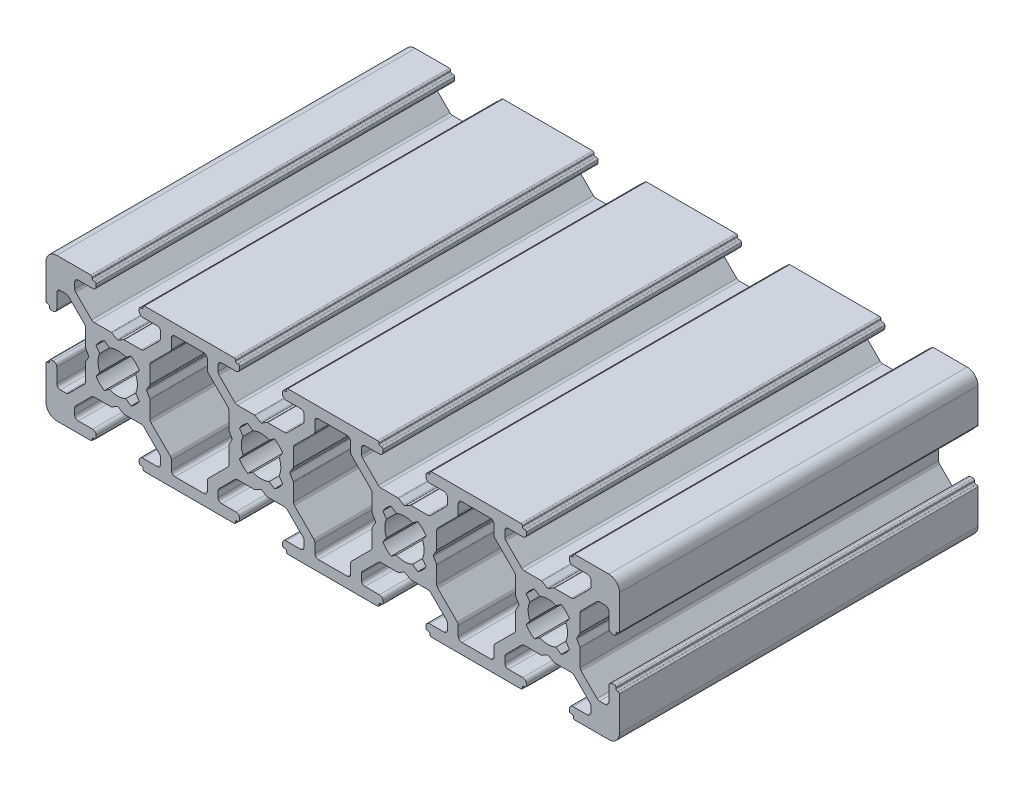
from build123d import *

# Parameters (mm, degrees)
EXTRUDE_1_DEPTH = 50


with BuildPart() as part:
    # Эскиз1 → Бобышка-Вытянуть1 (new body)
    with BuildSketch(Plane.XY):
        with BuildLine():
            Line((-13.645430713, 4.646446609), (-15.853553391, 6.854569287))
            ThreePointArc((-15.853553391, 6.854569287), (-15.961939766, 7.016780961), (-16, 7.208122677))
            Line((-16, 7.208122677), (-16, 8))
            ThreePointArc((-16, 8), (-15.853553391, 8.353553391), (-15.5, 8.5))
            Line((-15.5, 8.5), (-13.5, 8.5))
            ThreePointArc((-13.5, 8.5), (-13.146446609, 8.646446609), (-13, 9))
            Line((-13, 9), (-13, 9.3))
            ThreePointArc((-13, 9.3), (-13.058578644, 9.441421356), (-13.2, 9.5))
            Line((-13.2, 9.5), (-13.35, 9.5))
            ThreePointArc((-13.35, 9.5), (-13.491421356, 9.558578644), (-13.55, 9.7))
            Line((-13.55, 9.7), (-13.55, 9.8))
            ThreePointArc((-13.55, 9.8), (-13.608578644, 9.941421356), (-13.75, 10))
            Line((-13.75, 10), (-18.5, 10))
            ThreePointArc((-18.5, 10), (-19.560660172, 9.560660172), (-20, 8.5))
            Line((-20, 8.5), (-20, 3.75))
            ThreePointArc((-20, 3.75), (-19.941421356, 3.608578644), (-19.8, 3.55))
            Line((-19.8, 3.55), (-19.7, 3.55))
            ThreePointArc((-19.7, 3.55), (-19.558578644, 3.491421356), (-19.5, 3.35))
            Line((-19.5, 3.35), (-19.5, 3.2))
            ThreePointArc((-19.5, 3.2), (-19.441421356, 3.058578644), (-19.3, 3))
            Line((-19.3, 3), (-19, 3))
            ThreePointArc((-19, 3), (-18.646446609, 3.146446609), (-18.5, 3.5))
            Line((-18.5, 3.5), (-18.5, 5.5))
            ThreePointArc((-18.5, 5.5), (-18.353553391, 5.853553391), (-18, 6))
            Line((-18, 6), (-17.208122677, 6))
            ThreePointArc((-17.208122677, 6), (-17.016780961, 5.961939766), (-16.854569287, 5.853553391))
            Line((-16.854569287, 5.853553391), (-14.646446609, 3.645430713))
            ThreePointArc((-14.646446609, 3.645430713), (-14.538060234, 3.483219039), (-14.5, 3.291877323))
            Line((-14.5, 3.291877323), (-14.5, 0.919615242))
            ThreePointArc((-14.5, 0.919615242), (-14.493185165, 0.867851433), (-14.473205081, 0.819615242))
            Line((-14.473205081, 0.819615242), (-14.057735027, 0.1))
            ThreePointArc((-14.057735027, 0.1), (-14.030940108, 0), (-14.057735027, -0.1))
            Line((-14.057735027, -0.1), (-14.473205081, -0.819615242))
            ThreePointArc((-14.473205081, -0.819615242), (-14.493185165, -0.867851433), (-14.5, -0.919615242))
            Line((-14.5, -0.919615242), (-14.5, -3.291877323))
            ThreePointArc((-14.5, -3.291877323), (-14.538060234, -3.483219039), (-14.646446609, -3.645430713))
            Line((-14.646446609, -3.645430713), (-16.854569287, -5.853553391))
            ThreePointArc((-16.854569287, -5.853553391), (-17.016780961, -5.961939766), (-17.208122677, -6))
            Line((-17.208122677, -6), (-18, -6))
            ThreePointArc((-18, -6), (-18.353553391, -5.853553391), (-18.5, -5.5))
            Line((-18.5, -5.5), (-18.5, -3.5))
            ThreePointArc((-18.5, -3.5), (-18.646446609, -3.146446609), (-19, -3))
            Line((-19, -3), (-19.3, -3))
            ThreePointArc((-19.3, -3), (-19.441421356, -3.058578644), (-19.5, -3.2))
            Line((-19.5, -3.2), (-19.5, -3.35))
            ThreePointArc((-19.5, -3.35), (-19.558578644, -3.491421356), (-19.7, -3.55))
            Line((-19.7, -3.55), (-19.8, -3.55))
            ThreePointArc((-19.8, -3.55), (-19.941421356, -3.608578644), (-20, -3.75))
            Line((-20, -3.75), (-20, -8.5))
            ThreePointArc((-20, -8.5), (-19.560660172, -9.560660172), (-18.5, -10))
            Line((-18.5, -10), (-13.75, -10))
            ThreePointArc((-13.75, -10), (-13.608578644, -9.941421356), (-13.55, -9.8))
            Line((-13.55, -9.8), (-13.55, -9.7))
            ThreePointArc((-13.55, -9.7), (-13.491421356, -9.558578644), (-13.35, -9.5))
            Line((-13.35, -9.5), (-13.2, -9.5))
            ThreePointArc((-13.2, -9.5), (-13.058578644, -9.441421356), (-13, -9.3))
            Line((-13, -9.3), (-13, -9))
            ThreePointArc((-13, -9), (-13.146446609, -8.646446609), (-13.5, -8.5))
            Line((-13.5, -8.5), (-15.5, -8.5))
            ThreePointArc((-15.5, -8.5), (-15.853553391, -8.353553391), (-16, -8))
            Line((-16, -8), (-16, -7.208122677))
            ThreePointArc((-16, -7.208122677), (-15.961939766, -7.016780961), (-15.853553391, -6.854569287))
            Line((-15.853553391, -6.854569287), (-13.645430713, -4.646446609))
            ThreePointArc((-13.645430713, -4.646446609), (-13.483219039, -4.538060234), (-13.291877323, -4.5))
            Line((-13.291877323, -4.5), (-10.919615242, -4.5))
            ThreePointArc((-10.919615242, -4.5), (-10.867851433, -4.493185165), (-10.819615242, -4.473205081))
            Line((-10.819615242, -4.473205081), (-10.1, -4.057735027))
            ThreePointArc((-10.1, -4.057735027), (-10, -4.030940108), (-9.9, -4.057735027))
            Line((-9.9, -4.057735027), (-9.180384758, -4.473205081))
            ThreePointArc((-9.180384758, -4.473205081), (-9.132148567, -4.493185165), (-9.080384758, -4.5))
            Line((-9.080384758, -4.5), (-6.708122677, -4.5))
            ThreePointArc((-6.708122677, -4.5), (-6.516780961, -4.538060234), (-6.354569287, -4.646446609))
            Line((-6.354569287, -4.646446609), (-4.146446609, -6.854569287))
            ThreePointArc((-4.146446609, -6.854569287), (-4.038060234, -7.016780961), (-4, -7.208122677))
            Line((-4, -7.208122677), (-4, -8))
            ThreePointArc((-4, -8), (-4.146446609, -8.353553391), (-4.5, -8.5))
            Line((-4.5, -8.5), (-6.5, -8.5))
            ThreePointArc((-6.5, -8.5), (-6.853553391, -8.646446609), (-7, -9))
            Line((-7, -9), (-7, -9.3))
            ThreePointArc((-7, -9.3), (-6.941421356, -9.441421356), (-6.8, -9.5))
            Line((-6.8, -9.5), (-6.65, -9.5))
            ThreePointArc((-6.65, -9.5), (-6.508578644, -9.558578644), (-6.45, -9.7))
            Line((-6.45, -9.7), (-6.45, -9.8))
            ThreePointArc((-6.45, -9.8), (-6.391421356, -9.941421356), (-6.25, -10))
            Line((-6.25, -10), (6.25, -10))
            ThreePointArc((6.25, -10), (6.391421356, -9.941421356), (6.45, -9.8))
            Line((6.45, -9.8), (6.45, -9.7))
            ThreePointArc((6.45, -9.7), (6.508578644, -9.558578644), (6.65, -9.5))
            Line((6.65, -9.5), (6.8, -9.5))
            ThreePointArc((6.8, -9.5), (6.941421356, -9.441421356), (7, -9.3))
            Line((7, -9.3), (7, -9))
            ThreePointArc((7, -9), (6.853553391, -8.646446609), (6.5, -8.5))
            Line((6.5, -8.5), (4.5, -8.5))
            ThreePointArc((4.5, -8.5), (4.146446609, -8.353553391), (4, -8))
            Line((4, -8), (4, -7.208122677))
            ThreePointArc((4, -7.208122677), (4.038060234, -7.016780961), (4.146446609, -6.854569287))
            Line((4.146446609, -6.854569287), (6.354569287, -4.646446609))
            ThreePointArc((6.354569287, -4.646446609), (6.516780961, -4.538060234), (6.708122677, -4.5))
            Line((6.708122677, -4.5), (9.080384758, -4.5))
            ThreePointArc((9.080384758, -4.5), (9.132148567, -4.493185165), (9.180384758, -4.473205081))
            Line((9.180384758, -4.473205081), (9.9, -4.057735027))
            ThreePointArc((9.9, -4.057735027), (10, -4.030940108), (10.1, -4.057735027))
            Line((10.1, -4.057735027), (10.819615242, -4.473205081))
            ThreePointArc((10.819615242, -4.473205081), (10.867851433, -4.493185165), (10.919615242, -4.5))
            Line((10.919615242, -4.5), (13.291877323, -4.5))
            ThreePointArc((13.291877323, -4.5), (13.483219039, -4.538060234), (13.645430713, -4.646446609))
            Line((13.645430713, -4.646446609), (15.853553391, -6.854569287))
            ThreePointArc((15.853553391, -6.854569287), (15.961939766, -7.016780961), (16, -7.208122677))
            Line((16, -7.208122677), (16, -8))
            ThreePointArc((16, -8), (15.853553391, -8.353553391), (15.5, -8.5))
            Line((15.5, -8.5), (13.5, -8.5))
            ThreePointArc((13.5, -8.5), (13.146446609, -8.646446609), (13, -9))
            Line((13, -9), (13, -9.3))
            ThreePointArc((13, -9.3), (13.058578644, -9.441421356), (13.2, -9.5))
            Line((13.2, -9.5), (13.35, -9.5))
            ThreePointArc((13.35, -9.5), (13.491421356, -9.558578644), (13.55, -9.7))
            Line((13.55, -9.7), (13.55, -9.8))
            ThreePointArc((13.55, -9.8), (13.608578644, -9.941421356), (13.75, -10))
            Line((13.75, -10), (26.25, -10))
            ThreePointArc((26.25, -10), (26.391421356, -9.941421356), (26.45, -9.8))
            Line((26.45, -9.8), (26.45, -9.7))
            ThreePointArc((26.45, -9.7), (26.508578644, -9.558578644), (26.65, -9.5))
            Line((26.65, -9.5), (26.8, -9.5))
            ThreePointArc((26.8, -9.5), (26.941421356, -9.441421356), (27, -9.3))
            Line((27, -9.3), (27, -9))
            ThreePointArc((27, -9), (26.853553391, -8.646446609), (26.5, -8.5))
            Line((26.5, -8.5), (24.5, -8.5))
            ThreePointArc((24.5, -8.5), (24.146446609, -8.353553391), (24, -8))
            Line((24, -8), (24, -7.208122677))
            ThreePointArc((24, -7.208122677), (24.038060234, -7.016780961), (24.146446609, -6.854569287))
            Line((24.146446609, -6.854569287), (26.354569287, -4.646446609))
            ThreePointArc((26.354569287, -4.646446609), (26.516780961, -4.538060234), (26.708122677, -4.5))
            Line((26.708122677, -4.5), (29.080384758, -4.5))
            ThreePointArc((29.080384758, -4.5), (29.132148567, -4.493185165), (29.180384758, -4.473205081))
            Line((29.180384758, -4.473205081), (29.9, -4.057735027))
            ThreePointArc((29.9, -4.057735027), (30, -4.030940108), (30.1, -4.057735027))
            Line((30.1, -4.057735027), (30.819615242, -4.473205081))
            ThreePointArc((30.819615242, -4.473205081), (30.867851433, -4.493185165), (30.919615242, -4.5))
            Line((30.919615242, -4.5), (33.291877323, -4.5))
            ThreePointArc((33.291877323, -4.5), (33.483219039, -4.538060234), (33.645430713, -4.646446609))
            Line((33.645430713, -4.646446609), (35.853553391, -6.854569287))
            ThreePointArc((35.853553391, -6.854569287), (35.961939766, -7.016780961), (36, -7.208122677))
            Line((36, -7.208122677), (36, -8))
            ThreePointArc((36, -8), (35.853553391, -8.353553391), (35.5, -8.5))
            Line((35.5, -8.5), (33.5, -8.5))
            ThreePointArc((33.5, -8.5), (33.146446609, -8.646446609), (33, -9))
            Line((33, -9), (33, -9.3))
            ThreePointArc((33, -9.3), (33.058578644, -9.441421356), (33.2, -9.5))
            Line((33.2, -9.5), (33.35, -9.5))
            ThreePointArc((33.35, -9.5), (33.491421356, -9.558578644), (33.55, -9.7))
            Line((33.55, -9.7), (33.55, -9.8))
            ThreePointArc((33.55, -9.8), (33.608578644, -9.941421356), (33.75, -10))
            Line((33.75, -10), (46.25, -10))
            ThreePointArc((46.25, -10), (46.391421356, -9.941421356), (46.45, -9.8))
            Line((46.45, -9.8), (46.45, -9.7))
            ThreePointArc((46.45, -9.7), (46.508578644, -9.558578644), (46.65, -9.5))
            Line((46.65, -9.5), (46.8, -9.5))
            ThreePointArc((46.8, -9.5), (46.941421356, -9.441421356), (47, -9.3))
            Line((47, -9.3), (47, -9))
            ThreePointArc((47, -9), (46.853553391, -8.646446609), (46.5, -8.5))
            Line((46.5, -8.5), (44.5, -8.5))
            ThreePointArc((44.5, -8.5), (44.146446609, -8.353553391), (44, -8))
            Line((44, -8), (44, -7.208122677))
            ThreePointArc((44, -7.208122677), (44.038060234, -7.016780961), (44.146446609, -6.854569287))
            Line((44.146446609, -6.854569287), (46.354569287, -4.646446609))
            ThreePointArc((46.354569287, -4.646446609), (46.516780961, -4.538060234), (46.708122677, -4.5))
            Line((46.708122677, -4.5), (49.080384758, -4.5))
            ThreePointArc((49.080384758, -4.5), (49.132148567, -4.493185165), (49.180384758, -4.473205081))
            Line((49.180384758, -4.473205081), (49.9, -4.057735027))
            ThreePointArc((49.9, -4.057735027), (50, -4.030940108), (50.1, -4.057735027))
            Line((50.1, -4.057735027), (50.819615242, -4.473205081))
            ThreePointArc((50.819615242, -4.473205081), (50.867851433, -4.493185165), (50.919615242, -4.5))
            Line((50.919615242, -4.5), (53.291877323, -4.5))
            ThreePointArc((53.291877323, -4.5), (53.483219039, -4.538060234), (53.645430713, -4.646446609))
            Line((53.645430713, -4.646446609), (55.853553391, -6.854569287))
            ThreePointArc((55.853553391, -6.854569287), (55.961939766, -7.016780961), (56, -7.208122677))
            Line((56, -7.208122677), (56, -8))
            ThreePointArc((56, -8), (55.853553391, -8.353553391), (55.5, -8.5))
            Line((55.5, -8.5), (53.5, -8.5))
            ThreePointArc((53.5, -8.5), (53.146446609, -8.646446609), (53, -9))
            Line((53, -9), (53, -9.3))
            ThreePointArc((53, -9.3), (53.058578644, -9.441421356), (53.2, -9.5))
            Line((53.2, -9.5), (53.35, -9.5))
            ThreePointArc((53.35, -9.5), (53.491421356, -9.558578644), (53.55, -9.7))
            Line((53.55, -9.7), (53.55, -9.8))
            ThreePointArc((53.55, -9.8), (53.608578644, -9.941421356), (53.75, -10))
            Line((53.75, -10), (58.5, -10))
            ThreePointArc((58.5, -10), (59.560660172, -9.560660172), (60, -8.5))
            Line((60, -8.5), (60, -3.75))
            ThreePointArc((60, -3.75), (59.941421356, -3.608578644), (59.8, -3.55))
            Line((59.8, -3.55), (59.7, -3.55))
            ThreePointArc((59.7, -3.55), (59.558578644, -3.491421356), (59.5, -3.35))
            Line((59.5, -3.35), (59.5, -3.2))
            ThreePointArc((59.5, -3.2), (59.441421356, -3.058578644), (59.3, -3))
            Line((59.3, -3), (59, -3))
            ThreePointArc((59, -3), (58.646446609, -3.146446609), (58.5, -3.5))
            Line((58.5, -3.5), (58.5, -5.5))
            ThreePointArc((58.5, -5.5), (58.353553391, -5.853553391), (58, -6))
            Line((58, -6), (57.208122677, -6))
            ThreePointArc((57.208122677, -6), (57.016780961, -5.961939766), (56.854569287, -5.853553391))
            Line((56.854569287, -5.853553391), (54.646446609, -3.645430713))
            ThreePointArc((54.646446609, -3.645430713), (54.538060234, -3.483219039), (54.5, -3.291877323))
            Line((54.5, -3.291877323), (54.5, -0.919615242))
            ThreePointArc((54.5, -0.919615242), (54.493185165, -0.867851433), (54.473205081, -0.819615242))
            Line((54.473205081, -0.819615242), (54.057735027, -0.1))
            ThreePointArc((54.057735027, -0.1), (54.030940108, 0), (54.057735027, 0.1))
            Line((54.057735027, 0.1), (54.473205081, 0.819615242))
            ThreePointArc((54.473205081, 0.819615242), (54.493185165, 0.867851433), (54.5, 0.919615242))
            Line((54.5, 0.919615242), (54.5, 3.291877323))
            ThreePointArc((54.5, 3.291877323), (54.538060234, 3.483219039), (54.646446609, 3.645430713))
            Line((54.646446609, 3.645430713), (56.854569287, 5.853553391))
            ThreePointArc((56.854569287, 5.853553391), (57.016780961, 5.961939766), (57.208122677, 6))
            Line((57.208122677, 6), (58, 6))
            ThreePointArc((58, 6), (58.353553391, 5.853553391), (58.5, 5.5))
            Line((58.5, 5.5), (58.5, 3.5))
            ThreePointArc((58.5, 3.5), (58.646446609, 3.146446609), (59, 3))
            Line((59, 3), (59.3, 3))
            ThreePointArc((59.3, 3), (59.441421356, 3.058578644), (59.5, 3.2))
            Line((59.5, 3.2), (59.5, 3.35))
            ThreePointArc((59.5, 3.35), (59.558578644, 3.491421356), (59.7, 3.55))
            Line((59.7, 3.55), (59.8, 3.55))
            ThreePointArc((59.8, 3.55), (59.941421356, 3.608578644), (60, 3.75))
            Line((60, 3.75), (60, 8.5))
            ThreePointArc((60, 8.5), (59.560660172, 9.560660172), (58.5, 10))
            Line((58.5, 10), (53.75, 10))
            ThreePointArc((53.75, 10), (53.608578644, 9.941421356), (53.55, 9.8))
            Line((53.55, 9.8), (53.55, 9.7))
            ThreePointArc((53.55, 9.7), (53.491421356, 9.558578644), (53.35, 9.5))
            Line((53.35, 9.5), (53.2, 9.5))
            ThreePointArc((53.2, 9.5), (53.058578644, 9.441421356), (53, 9.3))
            Line((53, 9.3), (53, 9))
            ThreePointArc((53, 9), (53.146446609, 8.646446609), (53.5, 8.5))
            Line((53.5, 8.5), (55.5, 8.5))
            ThreePointArc((55.5, 8.5), (55.853553391, 8.353553391), (56, 8))
            Line((56, 8), (56, 7.208122677))
            ThreePointArc((56, 7.208122677), (55.961939766, 7.016780961), (55.853553391, 6.854569287))
            Line((55.853553391, 6.854569287), (53.645430713, 4.646446609))
            ThreePointArc((53.645430713, 4.646446609), (53.483219039, 4.538060234), (53.291877323, 4.5))
            Line((53.291877323, 4.5), (50.919615242, 4.5))
            ThreePointArc((50.919615242, 4.5), (50.867851433, 4.493185165), (50.819615242, 4.473205081))
            Line((50.819615242, 4.473205081), (50.1, 4.057735027))
            ThreePointArc((50.1, 4.057735027), (50, 4.030940108), (49.9, 4.057735027))
            Line((49.9, 4.057735027), (49.180384758, 4.473205081))
            ThreePointArc((49.180384758, 4.473205081), (49.132148567, 4.493185165), (49.080384758, 4.5))
            Line((49.080384758, 4.5), (46.708122677, 4.5))
            ThreePointArc((46.708122677, 4.5), (46.516780961, 4.538060234), (46.354569287, 4.646446609))
            Line((46.354569287, 4.646446609), (44.146446609, 6.854569287))
            ThreePointArc((44.146446609, 6.854569287), (44.038060234, 7.016780961), (44, 7.208122677))
            Line((44, 7.208122677), (44, 8))
            ThreePointArc((44, 8), (44.146446609, 8.353553391), (44.5, 8.5))
            Line((44.5, 8.5), (46.5, 8.5))
            ThreePointArc((46.5, 8.5), (46.853553391, 8.646446609), (47, 9))
            Line((47, 9), (47, 9.3))
            ThreePointArc((47, 9.3), (46.941421356, 9.441421356), (46.8, 9.5))
            Line((46.8, 9.5), (46.65, 9.5))
            ThreePointArc((46.65, 9.5), (46.508578644, 9.558578644), (46.45, 9.7))
            Line((46.45, 9.7), (46.45, 9.8))
            ThreePointArc((46.45, 9.8), (46.391421356, 9.941421356), (46.25, 10))
            Line((46.25, 10), (33.75, 10))
            ThreePointArc((33.75, 10), (33.608578644, 9.941421356), (33.55, 9.8))
            Line((33.55, 9.8), (33.55, 9.7))
            ThreePointArc((33.55, 9.7), (33.491421356, 9.558578644), (33.35, 9.5))
            Line((33.35, 9.5), (33.2, 9.5))
            ThreePointArc((33.2, 9.5), (33.058578644, 9.441421356), (33, 9.3))
            Line((33, 9.3), (33, 9))
            ThreePointArc((33, 9), (33.146446609, 8.646446609), (33.5, 8.5))
            Line((33.5, 8.5), (35.5, 8.5))
            ThreePointArc((35.5, 8.5), (35.853553391, 8.353553391), (36, 8))
            Line((36, 8), (36, 7.208122677))
            ThreePointArc((36, 7.208122677), (35.961939766, 7.016780961), (35.853553391, 6.854569287))
            Line((35.853553391, 6.854569287), (33.645430713, 4.646446609))
            ThreePointArc((33.645430713, 4.646446609), (33.483219039, 4.538060234), (33.291877323, 4.5))
            Line((33.291877323, 4.5), (30.919615242, 4.5))
            ThreePointArc((30.919615242, 4.5), (30.867851433, 4.493185165), (30.819615242, 4.473205081))
            Line((30.819615242, 4.473205081), (30.1, 4.057735027))
            ThreePointArc((30.1, 4.057735027), (30, 4.030940108), (29.9, 4.057735027))
            Line((29.9, 4.057735027), (29.180384758, 4.473205081))
            ThreePointArc((29.180384758, 4.473205081), (29.132148567, 4.493185165), (29.080384758, 4.5))
            Line((29.080384758, 4.5), (26.708122677, 4.5))
            ThreePointArc((26.708122677, 4.5), (26.516780961, 4.538060234), (26.354569287, 4.646446609))
            Line((26.354569287, 4.646446609), (24.146446609, 6.854569287))
            ThreePointArc((24.146446609, 6.854569287), (24.038060234, 7.016780961), (24, 7.208122677))
            Line((24, 7.208122677), (24, 8))
            ThreePointArc((24, 8), (24.146446609, 8.353553391), (24.5, 8.5))
            Line((24.5, 8.5), (26.5, 8.5))
            ThreePointArc((26.5, 8.5), (26.853553391, 8.646446609), (27, 9))
            Line((27, 9), (27, 9.3))
            ThreePointArc((27, 9.3), (26.941421356, 9.441421356), (26.8, 9.5))
            Line((26.8, 9.5), (26.65, 9.5))
            ThreePointArc((26.65, 9.5), (26.508578644, 9.558578644), (26.45, 9.7))
            Line((26.45, 9.7), (26.45, 9.8))
            ThreePointArc((26.45, 9.8), (26.391421356, 9.941421356), (26.25, 10))
            Line((26.25, 10), (13.75, 10))
            ThreePointArc((13.75, 10), (13.608578644, 9.941421356), (13.55, 9.8))
            Line((13.55, 9.8), (13.55, 9.7))
            ThreePointArc((13.55, 9.7), (13.491421356, 9.558578644), (13.35, 9.5))
            Line((13.35, 9.5), (13.2, 9.5))
            ThreePointArc((13.2, 9.5), (13.058578644, 9.441421356), (13, 9.3))
            Line((13, 9.3), (13, 9))
            ThreePointArc((13, 9), (13.146446609, 8.646446609), (13.5, 8.5))
            Line((13.5, 8.5), (15.5, 8.5))
            ThreePointArc((15.5, 8.5), (15.853553391, 8.353553391), (16, 8))
            Line((16, 8), (16, 7.208122677))
            ThreePointArc((16, 7.208122677), (15.961939766, 7.016780961), (15.853553391, 6.854569287))
            Line((15.853553391, 6.854569287), (13.645430713, 4.646446609))
            ThreePointArc((13.645430713, 4.646446609), (13.483219039, 4.538060234), (13.291877323, 4.5))
            Line((13.291877323, 4.5), (10.919615242, 4.5))
            ThreePointArc((10.919615242, 4.5), (10.867851433, 4.493185165), (10.819615242, 4.473205081))
            Line((10.819615242, 4.473205081), (10.1, 4.057735027))
            ThreePointArc((10.1, 4.057735027), (10, 4.030940108), (9.9, 4.057735027))
            Line((9.9, 4.057735027), (9.180384758, 4.473205081))
            ThreePointArc((9.180384758, 4.473205081), (9.132148567, 4.493185165), (9.080384758, 4.5))
            Line((9.080384758, 4.5), (6.708122677, 4.5))
            ThreePointArc((6.708122677, 4.5), (6.516780961, 4.538060234), (6.354569287, 4.646446609))
            Line((6.354569287, 4.646446609), (4.146446609, 6.854569287))
            ThreePointArc((4.146446609, 6.854569287), (4.038060234, 7.016780961), (4, 7.208122677))
            Line((4, 7.208122677), (4, 8))
            ThreePointArc((4, 8), (4.146446609, 8.353553391), (4.5, 8.5))
            Line((4.5, 8.5), (6.5, 8.5))
            ThreePointArc((6.5, 8.5), (6.853553391, 8.646446609), (7, 9))
            Line((7, 9), (7, 9.3))
            ThreePointArc((7, 9.3), (6.941421356, 9.441421356), (6.8, 9.5))
            Line((6.8, 9.5), (6.65, 9.5))
            ThreePointArc((6.65, 9.5), (6.508578644, 9.558578644), (6.45, 9.7))
            Line((6.45, 9.7), (6.45, 9.8))
            ThreePointArc((6.45, 9.8), (6.391421356, 9.941421356), (6.25, 10))
            Line((6.25, 10), (-6.25, 10))
            ThreePointArc((-6.25, 10), (-6.391421356, 9.941421356), (-6.45, 9.8))
            Line((-6.45, 9.8), (-6.45, 9.7))
            ThreePointArc((-6.45, 9.7), (-6.508578644, 9.558578644), (-6.65, 9.5))
            Line((-6.65, 9.5), (-6.8, 9.5))
            ThreePointArc((-6.8, 9.5), (-6.941421356, 9.441421356), (-7, 9.3))
            Line((-7, 9.3), (-7, 9))
            ThreePointArc((-7, 9), (-6.853553391, 8.646446609), (-6.5, 8.5))
            Line((-6.5, 8.5), (-4.5, 8.5))
            ThreePointArc((-4.5, 8.5), (-4.146446609, 8.353553391), (-4, 8))
            Line((-4, 8), (-4, 7.208122677))
            ThreePointArc((-4, 7.208122677), (-4.038060234, 7.016780961), (-4.146446609, 6.854569287))
            Line((-4.146446609, 6.854569287), (-6.354569287, 4.646446609))
            ThreePointArc((-6.354569287, 4.646446609), (-6.516780961, 4.538060234), (-6.708122677, 4.5))
            Line((-6.708122677, 4.5), (-9.080384758, 4.5))
            ThreePointArc((-9.080384758, 4.5), (-9.132148567, 4.493185165), (-9.180384758, 4.473205081))
            Line((-9.180384758, 4.473205081), (-9.9, 4.057735027))
            ThreePointArc((-9.9, 4.057735027), (-10, 4.030940108), (-10.1, 4.057735027))
            Line((-10.1, 4.057735027), (-10.819615242, 4.473205081))
            ThreePointArc((-10.819615242, 4.473205081), (-10.867851433, 4.493185165), (-10.919615242, 4.5))
            Line((-10.919615242, 4.5), (-13.291877323, 4.5))
            ThreePointArc((-13.291877323, 4.5), (-13.483219039, 4.538060234), (-13.645430713, 4.646446609))
        make_face()
        with BuildLine():
            Line((3.145430713, -5.853553391), (2.646446609, -6.352537495))
            ThreePointArc((2.646446609, -6.352537495), (2.538060234, -6.514749169), (2.5, -6.706090885))
            Line((2.5, -6.706090885), (2.5, -8))
            ThreePointArc((2.5, -8), (2.353553391, -8.353553391), (2, -8.5))
            Line((2, -8.5), (-2, -8.5))
            ThreePointArc((-2, -8.5), (-2.353553391, -8.353553391), (-2.5, -8))
            Line((-2.5, -8), (-2.5, -6.706090885))
            ThreePointArc((-2.5, -6.706090885), (-2.538060234, -6.514749169), (-2.646446609, -6.352537495))
            Line((-2.646446609, -6.352537495), (-3.145430713, -5.853553391))
            Line((-3.145430713, -5.853553391), (-5.353553391, -3.645430713))
            ThreePointArc((-5.353553391, -3.645430713), (-5.461939766, -3.483219039), (-5.5, -3.291877323))
            Line((-5.5, -3.291877323), (-5.5, -0.919615242))
            ThreePointArc((-5.5, -0.919615242), (-5.506814835, -0.867851433), (-5.526794919, -0.819615242))
            Line((-5.526794919, -0.819615242), (-5.942264973, -0.1))
            ThreePointArc((-5.942264973, -0.1), (-5.969059892, 0), (-5.942264973, 0.1))
            Line((-5.942264973, 0.1), (-5.526794919, 0.819615242))
            ThreePointArc((-5.526794919, 0.819615242), (-5.506814835, 0.867851433), (-5.5, 0.919615242))
            Line((-5.5, 0.919615242), (-5.5, 3.291877323))
            ThreePointArc((-5.5, 3.291877323), (-5.461939766, 3.483219039), (-5.353553391, 3.645430713))
            Line((-5.353553391, 3.645430713), (-3.145430713, 5.853553391))
            Line((-3.145430713, 5.853553391), (-2.646446609, 6.352537495))
            ThreePointArc((-2.646446609, 6.352537495), (-2.538060234, 6.514749169), (-2.5, 6.706090885))
            Line((-2.5, 6.706090885), (-2.5, 8))
            ThreePointArc((-2.5, 8), (-2.353553391, 8.353553391), (-2, 8.5))
            Line((-2, 8.5), (2, 8.5))
            ThreePointArc((2, 8.5), (2.353553391, 8.353553391), (2.5, 8))
            Line((2.5, 8), (2.5, 6.706090885))
            ThreePointArc((2.5, 6.706090885), (2.538060234, 6.514749169), (2.646446609, 6.352537495))
            Line((2.646446609, 6.352537495), (3.145430713, 5.853553391))
            Line((3.145430713, 5.853553391), (5.353553391, 3.645430713))
            ThreePointArc((5.353553391, 3.645430713), (5.461939766, 3.483219039), (5.5, 3.291877323))
            Line((5.5, 3.291877323), (5.5, 0.919615242))
            ThreePointArc((5.5, 0.919615242), (5.506814835, 0.867851433), (5.526794919, 0.819615242))
            Line((5.526794919, 0.819615242), (5.942264973, 0.1))
            ThreePointArc((5.942264973, 0.1), (5.969059892, 0), (5.942264973, -0.1))
            Line((5.942264973, -0.1), (5.526794919, -0.819615242))
            ThreePointArc((5.526794919, -0.819615242), (5.506814835, -0.867851433), (5.5, -0.919615242))
            Line((5.5, -0.919615242), (5.5, -3.291877323))
            ThreePointArc((5.5, -3.291877323), (5.461939766, -3.483219039), (5.353553391, -3.645430713))
            Line((5.353553391, -3.645430713), (3.145430713, -5.853553391))
        make_face(mode=Mode.SUBTRACT)
        with BuildLine():
            Line((-13.020442772, 1.865321812), (-12.506504586, 1.131342017))
            ThreePointArc((-12.506504586, 1.131342017), (-12.75, 0), (-12.506504586, -1.131342017))
            Line((-12.506504586, -1.131342017), (-13.020442772, -1.865321812))
            ThreePointArc((-13.020442772, -1.865321812), (-12.510229073, -2.510229073), (-11.865321812, -3.020442772))
            Line((-11.865321812, -3.020442772), (-11.131342017, -2.506504586))
            ThreePointArc((-11.131342017, -2.506504586), (-10, -2.75), (-8.868657983, -2.506504586))
            Line((-8.868657983, -2.506504586), (-8.134678188, -3.020442772))
            ThreePointArc((-8.134678188, -3.020442772), (-7.489770927, -2.510229073), (-6.979557228, -1.865321812))
            Line((-6.979557228, -1.865321812), (-7.493495414, -1.131342017))
            ThreePointArc((-7.493495414, -1.131342017), (-7.25, 0), (-7.493495414, 1.131342017))
            Line((-7.493495414, 1.131342017), (-6.979557228, 1.865321812))
            ThreePointArc((-6.979557228, 1.865321812), (-7.489770927, 2.510229073), (-8.134678188, 3.020442772))
            Line((-8.134678188, 3.020442772), (-8.868657983, 2.506504586))
            ThreePointArc((-8.868657983, 2.506504586), (-10, 2.75), (-11.131342017, 2.506504586))
            Line((-11.131342017, 2.506504586), (-11.865321812, 3.020442772))
            ThreePointArc((-11.865321812, 3.020442772), (-12.510229073, 2.510229073), (-13.020442772, 1.865321812))
        make_face(mode=Mode.SUBTRACT)
        with BuildLine():
            Line((14.5, -0.919615242), (14.5, -3.291877323))
            ThreePointArc((14.5, -3.291877323), (14.538060234, -3.483219039), (14.646446609, -3.645430713))
            Line((14.646446609, -3.645430713), (16.854569287, -5.853553391))
            Line((16.854569287, -5.853553391), (17.353553391, -6.352537495))
            ThreePointArc((17.353553391, -6.352537495), (17.461939766, -6.514749169), (17.5, -6.706090885))
            Line((17.5, -6.706090885), (17.5, -8))
            ThreePointArc((17.5, -8), (17.646446609, -8.353553391), (18, -8.5))
            Line((18, -8.5), (22, -8.5))
            ThreePointArc((22, -8.5), (22.353553391, -8.353553391), (22.5, -8))
            Line((22.5, -8), (22.5, -6.706090885))
            ThreePointArc((22.5, -6.706090885), (22.538060234, -6.514749169), (22.646446609, -6.352537495))
            Line((22.646446609, -6.352537495), (23.145430713, -5.853553391))
            Line((23.145430713, -5.853553391), (25.353553391, -3.645430713))
            ThreePointArc((25.353553391, -3.645430713), (25.461939766, -3.483219039), (25.5, -3.291877323))
            Line((25.5, -3.291877323), (25.5, -0.919615242))
            ThreePointArc((25.5, -0.919615242), (25.506814835, -0.867851433), (25.526794919, -0.819615242))
            Line((25.526794919, -0.819615242), (25.942264973, -0.1))
            ThreePointArc((25.942264973, -0.1), (25.969059892, 0), (25.942264973, 0.1))
            Line((25.942264973, 0.1), (25.526794919, 0.819615242))
            ThreePointArc((25.526794919, 0.819615242), (25.506814835, 0.867851433), (25.5, 0.919615242))
            Line((25.5, 0.919615242), (25.5, 3.291877323))
            ThreePointArc((25.5, 3.291877323), (25.461939766, 3.483219039), (25.353553391, 3.645430713))
            Line((25.353553391, 3.645430713), (23.145430713, 5.853553391))
            Line((23.145430713, 5.853553391), (22.646446609, 6.352537495))
            ThreePointArc((22.646446609, 6.352537495), (22.538060234, 6.514749169), (22.5, 6.706090885))
            Line((22.5, 6.706090885), (22.5, 8))
            ThreePointArc((22.5, 8), (22.353553391, 8.353553391), (22, 8.5))
            Line((22, 8.5), (18, 8.5))
            ThreePointArc((18, 8.5), (17.646446609, 8.353553391), (17.5, 8))
            Line((17.5, 8), (17.5, 6.706090885))
            ThreePointArc((17.5, 6.706090885), (17.461939766, 6.514749169), (17.353553391, 6.352537495))
            Line((17.353553391, 6.352537495), (16.854569287, 5.853553391))
            Line((16.854569287, 5.853553391), (14.646446609, 3.645430713))
            ThreePointArc((14.646446609, 3.645430713), (14.538060234, 3.483219039), (14.5, 3.291877323))
            Line((14.5, 3.291877323), (14.5, 0.919615242))
            ThreePointArc((14.5, 0.919615242), (14.493185165, 0.867851433), (14.473205081, 0.819615242))
            Line((14.473205081, 0.819615242), (14.057735027, 0.1))
            ThreePointArc((14.057735027, 0.1), (14.030940108, 0), (14.057735027, -0.1))
            Line((14.057735027, -0.1), (14.473205081, -0.819615242))
            ThreePointArc((14.473205081, -0.819615242), (14.493185165, -0.867851433), (14.5, -0.919615242))
        make_face(mode=Mode.SUBTRACT)
        with BuildLine():
            Line((13.020442772, -1.865321812), (12.506504586, -1.131342017))
            ThreePointArc((12.506504586, -1.131342017), (12.75, 0), (12.506504586, 1.131342017))
            Line((12.506504586, 1.131342017), (13.020442772, 1.865321812))
            ThreePointArc((13.020442772, 1.865321812), (12.510229073, 2.510229073), (11.865321812, 3.020442772))
            Line((11.865321812, 3.020442772), (11.131342017, 2.506504586))
            ThreePointArc((11.131342017, 2.506504586), (10, 2.75), (8.868657983, 2.506504586))
            Line((8.868657983, 2.506504586), (8.134678188, 3.020442772))
            ThreePointArc((8.134678188, 3.020442772), (7.489770927, 2.510229073), (6.979557228, 1.865321812))
            Line((6.979557228, 1.865321812), (7.493495414, 1.131342017))
            ThreePointArc((7.493495414, 1.131342017), (7.25, 0), (7.493495414, -1.131342017))
            Line((7.493495414, -1.131342017), (6.979557228, -1.865321812))
            ThreePointArc((6.979557228, -1.865321812), (7.489770927, -2.510229073), (8.134678188, -3.020442772))
            Line((8.134678188, -3.020442772), (8.868657983, -2.506504586))
            ThreePointArc((8.868657983, -2.506504586), (10, -2.75), (11.131342017, -2.506504586))
            Line((11.131342017, -2.506504586), (11.865321812, -3.020442772))
            ThreePointArc((11.865321812, -3.020442772), (12.510229073, -2.510229073), (13.020442772, -1.865321812))
        make_face(mode=Mode.SUBTRACT)
        with BuildLine():
            Line((26.979557228, -1.865321812), (27.493495414, -1.131342017))
            ThreePointArc((27.493495414, -1.131342017), (27.25, 0), (27.493495414, 1.131342017))
            Line((27.493495414, 1.131342017), (26.979557228, 1.865321812))
            ThreePointArc((26.979557228, 1.865321812), (27.489770927, 2.510229073), (28.134678188, 3.020442772))
            Line((28.134678188, 3.020442772), (28.868657983, 2.506504586))
            ThreePointArc((28.868657983, 2.506504586), (30, 2.75), (31.131342017, 2.506504586))
            Line((31.131342017, 2.506504586), (31.865321812, 3.020442772))
            ThreePointArc((31.865321812, 3.020442772), (32.510229073, 2.510229073), (33.020442772, 1.865321812))
            Line((33.020442772, 1.865321812), (32.506504586, 1.131342017))
            ThreePointArc((32.506504586, 1.131342017), (32.75, 0), (32.506504586, -1.131342017))
            Line((32.506504586, -1.131342017), (33.020442772, -1.865321812))
            ThreePointArc((33.020442772, -1.865321812), (32.510229073, -2.510229073), (31.865321812, -3.020442772))
            Line((31.865321812, -3.020442772), (31.131342017, -2.506504586))
            ThreePointArc((31.131342017, -2.506504586), (30, -2.75), (28.868657983, -2.506504586))
            Line((28.868657983, -2.506504586), (28.134678188, -3.020442772))
            ThreePointArc((28.134678188, -3.020442772), (27.489770927, -2.510229073), (26.979557228, -1.865321812))
        make_face(mode=Mode.SUBTRACT)
        with BuildLine():
            Line((34.5, -0.919615242), (34.5, -3.291877323))
            ThreePointArc((34.5, -3.291877323), (34.538060234, -3.483219039), (34.646446609, -3.645430713))
            Line((34.646446609, -3.645430713), (36.854569287, -5.853553391))
            Line((36.854569287, -5.853553391), (37.353553391, -6.352537495))
            ThreePointArc((37.353553391, -6.352537495), (37.461939766, -6.514749169), (37.5, -6.706090885))
            Line((37.5, -6.706090885), (37.5, -8))
            ThreePointArc((37.5, -8), (37.646446609, -8.353553391), (38, -8.5))
            Line((38, -8.5), (42, -8.5))
            ThreePointArc((42, -8.5), (42.353553391, -8.353553391), (42.5, -8))
            Line((42.5, -8), (42.5, -6.706090885))
            ThreePointArc((42.5, -6.706090885), (42.538060234, -6.514749169), (42.646446609, -6.352537495))
            Line((42.646446609, -6.352537495), (43.145430713, -5.853553391))
            Line((43.145430713, -5.853553391), (45.353553391, -3.645430713))
            ThreePointArc((45.353553391, -3.645430713), (45.461939766, -3.483219039), (45.5, -3.291877323))
            Line((45.5, -3.291877323), (45.5, -0.919615242))
            ThreePointArc((45.5, -0.919615242), (45.506814835, -0.867851433), (45.526794919, -0.819615242))
            Line((45.526794919, -0.819615242), (45.942264973, -0.1))
            ThreePointArc((45.942264973, -0.1), (45.969059892, 0), (45.942264973, 0.1))
            Line((45.942264973, 0.1), (45.526794919, 0.819615242))
            ThreePointArc((45.526794919, 0.819615242), (45.506814835, 0.867851433), (45.5, 0.919615242))
            Line((45.5, 0.919615242), (45.5, 3.291877323))
            ThreePointArc((45.5, 3.291877323), (45.461939766, 3.483219039), (45.353553391, 3.645430713))
            Line((45.353553391, 3.645430713), (43.145430713, 5.853553391))
            Line((43.145430713, 5.853553391), (42.646446609, 6.352537495))
            ThreePointArc((42.646446609, 6.352537495), (42.538060234, 6.514749169), (42.5, 6.706090885))
            Line((42.5, 6.706090885), (42.5, 8))
            ThreePointArc((42.5, 8), (42.353553391, 8.353553391), (42, 8.5))
            Line((42, 8.5), (38, 8.5))
            ThreePointArc((38, 8.5), (37.646446609, 8.353553391), (37.5, 8))
            Line((37.5, 8), (37.5, 6.706090885))
            ThreePointArc((37.5, 6.706090885), (37.461939766, 6.514749169), (37.353553391, 6.352537495))
            Line((37.353553391, 6.352537495), (36.854569287, 5.853553391))
            Line((36.854569287, 5.853553391), (34.646446609, 3.645430713))
            ThreePointArc((34.646446609, 3.645430713), (34.538060234, 3.483219039), (34.5, 3.291877323))
            Line((34.5, 3.291877323), (34.5, 0.919615242))
            ThreePointArc((34.5, 0.919615242), (34.493185165, 0.867851433), (34.473205081, 0.819615242))
            Line((34.473205081, 0.819615242), (34.057735027, 0.1))
            ThreePointArc((34.057735027, 0.1), (34.030940108, 0), (34.057735027, -0.1))
            Line((34.057735027, -0.1), (34.473205081, -0.819615242))
            ThreePointArc((34.473205081, -0.819615242), (34.493185165, -0.867851433), (34.5, -0.919615242))
        make_face(mode=Mode.SUBTRACT)
        with BuildLine():
            Line((53.020442772, -1.865321812), (52.506504586, -1.131342017))
            ThreePointArc((52.506504586, -1.131342017), (52.75, 0), (52.506504586, 1.131342017))
            Line((52.506504586, 1.131342017), (53.020442772, 1.865321812))
            ThreePointArc((53.020442772, 1.865321812), (52.510229073, 2.510229073), (51.865321812, 3.020442772))
            Line((51.865321812, 3.020442772), (51.131342017, 2.506504586))
            ThreePointArc((51.131342017, 2.506504586), (50, 2.75), (48.868657983, 2.506504586))
            Line((48.868657983, 2.506504586), (48.134678188, 3.020442772))
            ThreePointArc((48.134678188, 3.020442772), (47.489770927, 2.510229073), (46.979557228, 1.865321812))
            Line((46.979557228, 1.865321812), (47.493495414, 1.131342017))
            ThreePointArc((47.493495414, 1.131342017), (47.25, 0), (47.493495414, -1.131342017))
            Line((47.493495414, -1.131342017), (46.979557228, -1.865321812))
            ThreePointArc((46.979557228, -1.865321812), (47.489770927, -2.510229073), (48.134678188, -3.020442772))
            Line((48.134678188, -3.020442772), (48.868657983, -2.506504586))
            ThreePointArc((48.868657983, -2.506504586), (50, -2.75), (51.131342017, -2.506504586))
            Line((51.131342017, -2.506504586), (51.865321812, -3.020442772))
            ThreePointArc((51.865321812, -3.020442772), (52.510229073, -2.510229073), (53.020442772, -1.865321812))
        make_face(mode=Mode.SUBTRACT)
    extrude(amount=EXTRUDE_1_DEPTH)


solid = part.part
